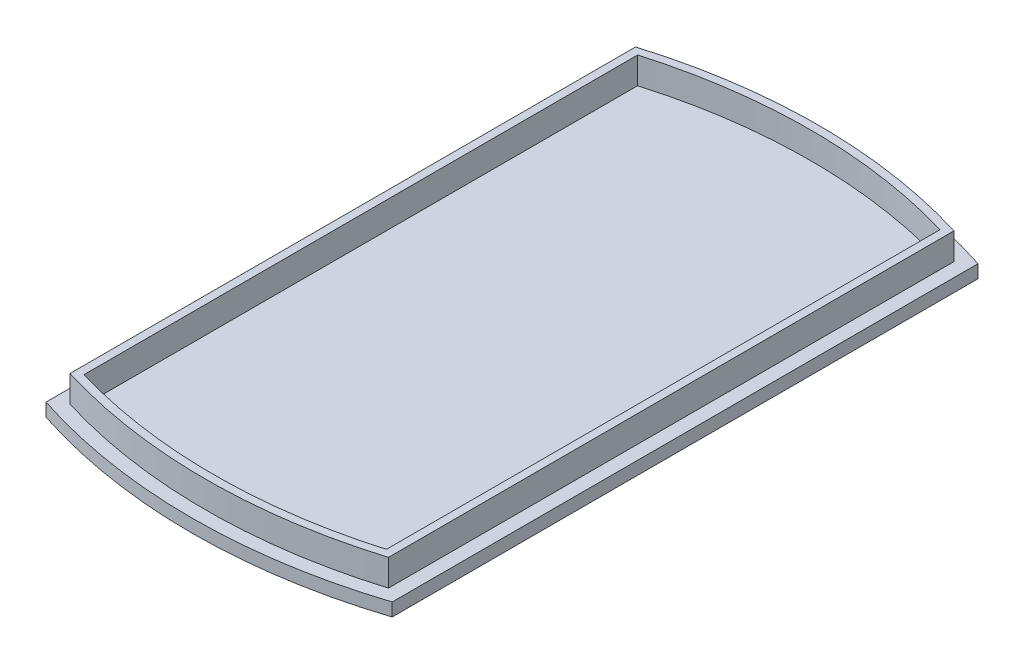
from build123d import *

# Parameters (mm, degrees)
BOSS_EXTRUDE1_DEPTH = 7
BOSS_EXTRUDE2_DEPTH = 5
CHAMFER1_SIZE       = 12.5
CHAMFER1_SIZE2      = 4.549627928


with BuildPart() as part:
    # Sketch1 → Boss-Extrude1 (new body)
    with BuildSketch(Plane(origin=(0, 0, 0), x_dir=(1, 0, 0), z_dir=(0, 1, 0))):
        with BuildLine():
            Line((-32.5, 55), (-32.5, -55))
            ThreePointArc((-32.5, -55), (0, -60.156372261), (32.5, -55))
            Line((32.5, -55), (32.5, 55))
            ThreePointArc((32.5, 55), (0, 60.156372261), (-32.5, 55))
        make_face()
    extrude(amount=BOSS_EXTRUDE1_DEPTH)

    # Sketch2 → Boss-Extrude2 (add)
    with BuildSketch(Plane(origin=(0, 7, 0), x_dir=(1, 0, 0), z_dir=(0, 1, 0))):
        with BuildLine():
            Line((29.9, -53.093852319), (29.9, 53.093852319))
            ThreePointArc((29.9, 53.093852319), (0, 57.556372261), (-29.9, 53.093852319))
            Line((-29.9, 53.093852319), (-29.9, -53.093852319))
            ThreePointArc((-29.9, -53.093852319), (0, -57.556372261), (29.9, -53.093852319))
        make_face()
        with BuildLine():
            Line((28.4, -51.977082856), (28.4, 51.977082856))
            ThreePointArc((28.4, 51.977082856), (0, 56.056372261), (-28.4, 51.977082856))
            Line((-28.4, 51.977082856), (-28.4, -51.977082856))
            ThreePointArc((-28.4, -51.977082856), (0, -56.056372261), (28.4, -51.977082856))
        make_face(mode=Mode.SUBTRACT)
    extrude(amount=BOSS_EXTRUDE2_DEPTH)

    # Chamfer1
    chamfer1_edges = [part.edges().sort_by_distance(p)[0] for p in [
        (-32.5, 0, 0),
        (0, 0, -60.156372261),
        (32.5, 0, 0),
        (0, 0, 60.156372261),
    ]]
    chamfer1_side = [part.faces().sort_by_distance(p)[0] for p in [
        (0, 0, 0),
    ]]
    chamfer(chamfer1_edges, length=CHAMFER1_SIZE, length2=CHAMFER1_SIZE2, reference=chamfer1_side[0])


solid = part.part
